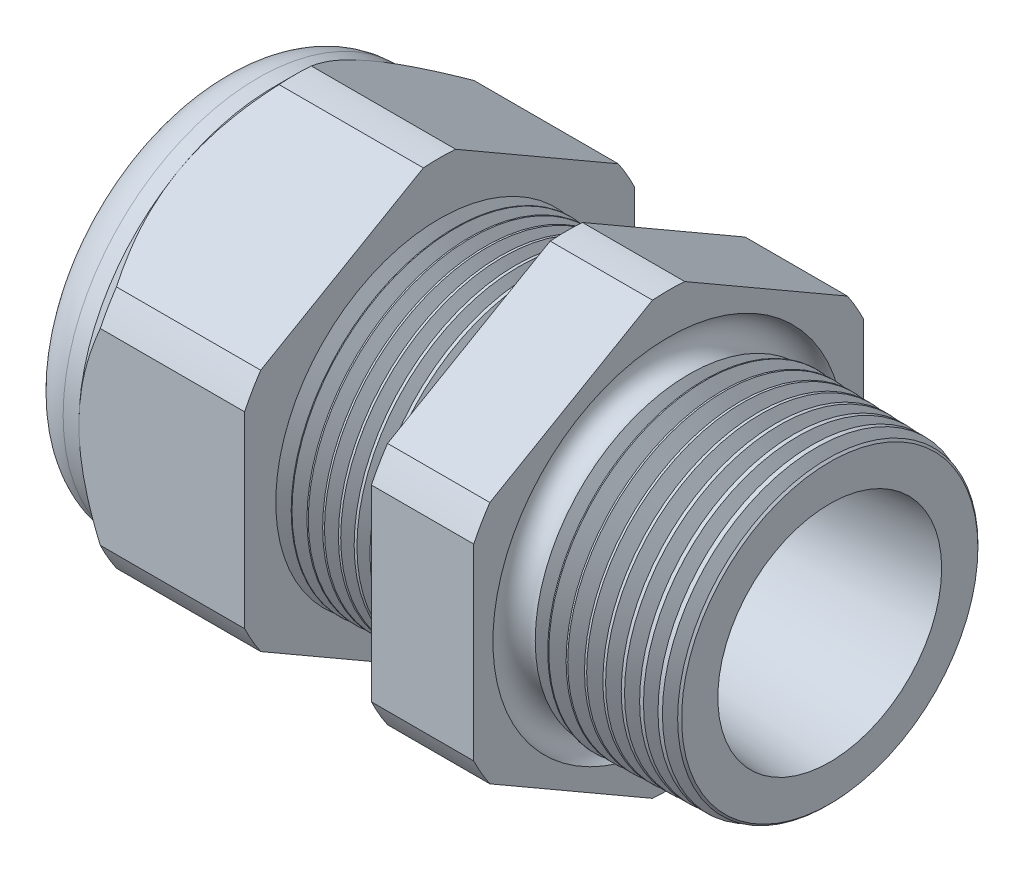
from build123d import *

# Parameters (mm, degrees)
SKETCH12_OUTSIDE_W = 52.432
SKETCH12_OUTSIDE_H = 52.432
CUT_EXTRUDE2_DEPTH = 28.172
FILLET4_R          = 2.032
SKETCH19_OUTSIDE_W = 33.316
SKETCH19_OUTSIDE_H = 35.412
SKETCH19_OUTSIDE_R = 9.525
CUT_EXTRUDE3_DEPTH = 1.999996
CUT_EXTRUDE3_DRAFT = -45
CHAMFER1_SIZE      = 0.260919487
CHAMFER1_SIZE2     = 0.254
SKETCH21_R         = 3.937
PLUG_DEPTH         = 3.81
SKETCH22_R         = 3.683
CUT_EXTRUDE4_DEPTH = 0.508
SKETCH27_R         = 0.889
PLUGHOLES_DEPTH    = 30.464
CIRPATTERN1_COUNT  = 3
LPATTERN1_COUNT    = 8
LPATTERN1_PITCH    = 0.762
LPATTERN2_COUNT    = 9
LPATTERN2_PITCH    = 0.889
SKETCH32_R         = 0.889


with BuildPart() as part:
    # Sketch10 → Revolve2 (revolve)
    with BuildSketch(Plane.XY, mode=Mode.PRIVATE) as revolve2_sk:
        Polygon((-29.972, 3.937), (-19.072, 3.937), (0, 5.469582104), (0, 7.501582104), (-7.874, 7.70777005), (-7.874, 19.05), (-12.874, 19.05), (-12.874, 7.838699658), (-19.072, 8.001), (-19.072, 19.05), (-27.172, 19.05), (-27.172, 9.525), (-29.972, 9.525), align=None)
    revolve(revolve2_sk.sketch.rotate(Axis((0, 0, 0), (-1, 0, 0)), 90), axis=Axis((0, 0, 0), (-1, 0, 0)))  # turned: the seam where the file's is

    # Sketch12 outside → Cut-Extrude2 (cut, through all)
    with BuildSketch(Plane.ZY.offset(27.172)):
        Rectangle(SKETCH12_OUTSIDE_W, SKETCH12_OUTSIDE_H)
        with BuildLine():
            Line((-0.788451287, 10.543310065), (-8.736548713, 5.954473877))
            ThreePointArc((-8.736548713, 5.954473877), (-9.156270088, 5.286375), (-9.525, 4.588836188))
            Line((-9.525, 4.588836188), (-9.525, -4.588836188))
            ThreePointArc((-9.525, -4.588836188), (-9.156270088, -5.286375), (-8.736548713, -5.954473877))
            Line((-8.736548713, -5.954473877), (-0.788451287, -10.543310065))
            ThreePointArc((-0.788451287, -10.543310065), (0, -10.57275), (0.788451287, -10.543310065))
            Line((0.788451287, -10.543310065), (8.736548713, -5.954473877))
            ThreePointArc((8.736548713, -5.954473877), (9.156270088, -5.286375), (9.525, -4.588836188))
            Line((9.525, -4.588836188), (9.525, 4.588836188))
            ThreePointArc((9.525, 4.588836188), (9.156270088, 5.286375), (8.736548713, 5.954473877))
            Line((8.736548713, 5.954473877), (0.788451287, 10.543310065))
            ThreePointArc((0.788451287, 10.543310065), (0, 10.57275), (-0.788451287, 10.543310065))
        make_face(mode=Mode.SUBTRACT)
    extrude(amount=-CUT_EXTRUDE2_DEPTH, mode=Mode.SUBTRACT)

    # Fillet4
    fillet4_edges = [part.edges().sort_by_distance(p)[0] for p in [
        (-29.972, 0, 9.525),
    ]]
    fillet(fillet4_edges, radius=FILLET4_R)


with BuildPart() as cut_extrude3_tool:
    # Sketch19 outside → Cut-Extrude3 (with draft: the straight prism first)
    with BuildSketch(Plane.ZY.offset(27.172)):
        Rectangle(SKETCH19_OUTSIDE_W, SKETCH19_OUTSIDE_H)
        Circle(SKETCH19_OUTSIDE_R, mode=Mode.SUBTRACT)
    extrude(amount=-CUT_EXTRUDE3_DEPTH)
    # Cut-Extrude3: the draft: its side faces are tilted about the plane it starts from
    cut_extrude3_sides = [cut_extrude3_tool.faces().sort_by_distance(p)[0] for p in [
        (-26.172002, -17.706, 0),
        (-26.172002, 0, 16.658),
        (-26.172002, 17.706, 0),
        (-26.172002, 0, -16.658),
        (-26.172002, 0, -9.525),
    ]]
    draft(cut_extrude3_sides, Plane.ZY.offset(27.172), CUT_EXTRUDE3_DRAFT)


with BuildPart() as part_1:
    add(part.part)

    # Cut-Extrude3: cut by cut_extrude3_tool
    add(cut_extrude3_tool.part, mode=Mode.SUBTRACT)

    # Chamfer1
    chamfer1_edges = [part_1.edges().sort_by_distance(p)[0] for p in [
        (0, 0, 7.501582104),
    ]]
    chamfer1_side = [part_1.faces().sort_by_distance(p)[0] for p in [
        (0, 0, 5.681758887),
    ]]
    chamfer(chamfer1_edges, length=CHAMFER1_SIZE, length2=CHAMFER1_SIZE2, reference=chamfer1_side[0])

    # Sketch29 → Cut-Revolve1 (revolve, cut)
    with BuildSketch(Plane.XY, mode=Mode.PRIVATE) as cut_revolve1_sk:
        Polygon((-19.072, 8.001), (-18.339016419, 7.981806149), (-18.722130572, 7.356620673), align=None)
    cut_revolve1 = revolve(cut_revolve1_sk.sketch.rotate(Axis((0, 0, 0), (-1, 0, 0)), 90), axis=Axis((0, 0, 0), (-1, 0, 0)), mode=Mode.SUBTRACT)  # turned: the seam where the file's is

    # LPattern1: Cut-Revolve1 ×8
    with Locations(*[(i * LPATTERN1_PITCH, 0, 0) for i in range(1, LPATTERN1_COUNT)]):
        add(cut_revolve1, mode=Mode.SUBTRACT)

    # Sketch30 → Cut-Revolve2 (revolve, cut)
    with BuildSketch(Plane.XY, mode=Mode.PRIVATE) as cut_revolve2_sk:
        Polygon((-7.874, 7.70777005), (-6.994419703, 7.68473743), (-7.454156686, 6.934514858), align=None)
    cut_revolve2 = revolve(cut_revolve2_sk.sketch.rotate(Axis((0, 0, 0), (-1, 0, 0)), 270), axis=Axis((0, 0, 0), (-1, 0, 0)), mode=Mode.SUBTRACT)  # turned: the seam where the file's is

    # LPattern2: Cut-Revolve2 ×9
    with Locations(*[(i * LPATTERN2_PITCH, 0, 0) for i in range(1, LPATTERN2_COUNT)]):
        add(cut_revolve2, mode=Mode.SUBTRACT)

    # Sketch32 → Cut-Revolve3 (revolve, cut)
    with BuildSketch(Plane.XY, mode=Mode.PRIVATE) as cut_revolve3_sk:
        with Locations((-7.747, 7.70777005)):
            Circle(SKETCH32_R)
    revolve(cut_revolve3_sk.sketch.rotate(Axis((0, 0, 0), (-1, 0, 0)), 270), axis=Axis((0, 0, 0), (-1, 0, 0)), mode=Mode.SUBTRACT)  # turned: the seam where the file's is


with BuildPart() as body_2:
    # Sketch21 → plug (new body)
    with BuildSketch(Plane.ZY.offset(29.972)):
        Circle(SKETCH21_R)
    extrude(amount=-PLUG_DEPTH)

    # Sketch22 → Cut-Extrude4 (cut)
    with BuildSketch(Plane.ZY.offset(29.972)):
        Circle(SKETCH22_R)
    extrude(amount=-CUT_EXTRUDE4_DEPTH, mode=Mode.SUBTRACT)

    # Sketch27 → plugholes (cut, through all)
    with BuildSketch(Plane.ZY.offset(29.464)):
        with Locations((-2.790444, 0)):
            Circle(SKETCH27_R)
    plugholes = extrude(amount=-PLUGHOLES_DEPTH, mode=Mode.SUBTRACT)

    # CirPattern1: plugholes ×3 about axis
    cirpattern1_axis = Axis((0, 0, 0), (1, 0, 0))
    for i in range(1, CIRPATTERN1_COUNT):
        add(plugholes.rotate(cirpattern1_axis, i * 360 / CIRPATTERN1_COUNT), mode=Mode.SUBTRACT)


solid = Compound([part_1.part, body_2.part])
